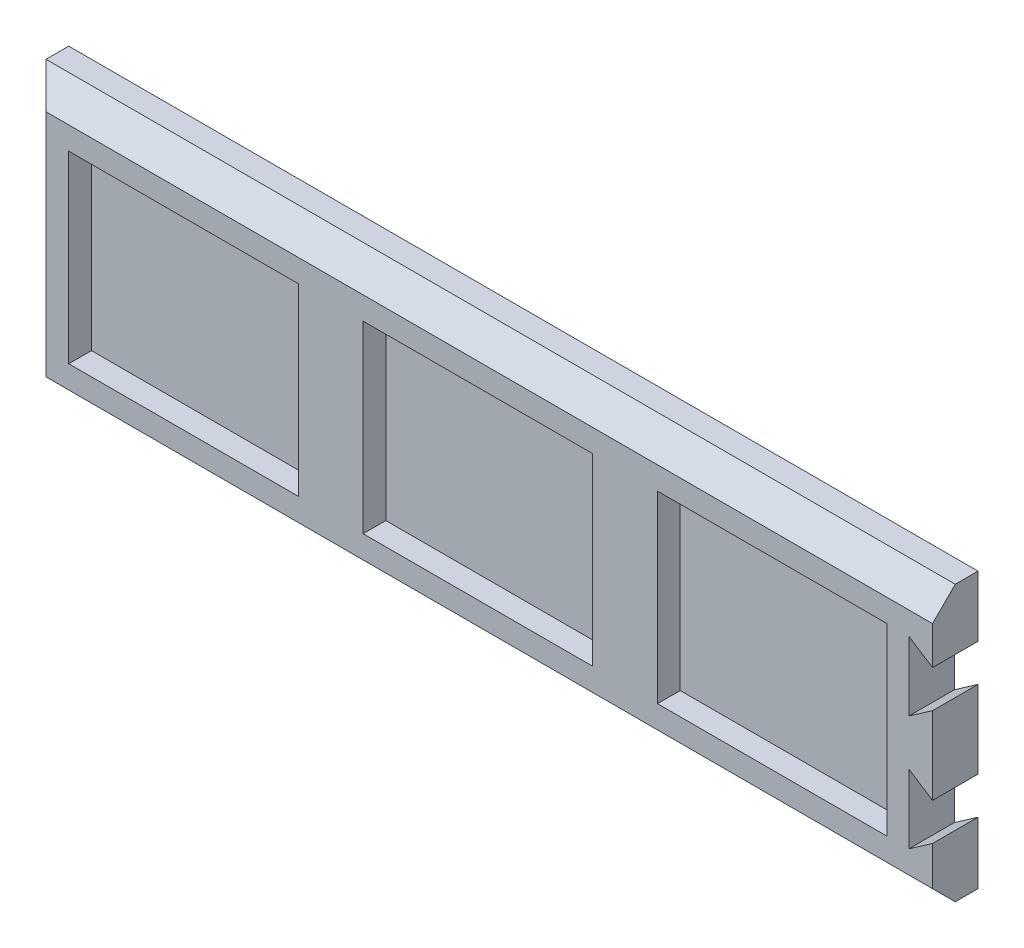
from build123d import *

# Parameters (mm, degrees)
SKIZZE1_W                       = 200
SKIZZE1_H                       = 60.5
AUFSATZ_LINEAR_AUSTRAGEN1_DEPTH = 10
SKIZZE2_W                       = 50.5
SKIZZE2_H                       = 40.5
SCHNITT_LINEAR_AUSTRAGEN1_DEPTH = 5
FASE1_SIZE                      = 5
SCHNITT_LINEAR_AUSTRAGEN2_DEPTH = 10


with BuildPart() as part:
    # Skizze1 → Aufsatz-Linear austragen1 (new body)
    with BuildSketch(Plane.XY):
        with Locations((100, 0)):
            Rectangle(SKIZZE1_W, SKIZZE1_H)
    extrude(amount=AUFSATZ_LINEAR_AUSTRAGEN1_DEPTH)

    # Skizze2 → Schnitt-Linear austragen1 (cut)
    with BuildSketch(Plane.XY.offset(10)):
        with Locations((35.25, 0)):
            Rectangle(SKIZZE2_W, SKIZZE2_H)
        with Locations((100, 0)):
            Rectangle(SKIZZE2_W, SKIZZE2_H)
        with Locations((164.75, 0)):
            Rectangle(SKIZZE2_W, SKIZZE2_H)
    extrude(amount=-SCHNITT_LINEAR_AUSTRAGEN1_DEPTH, mode=Mode.SUBTRACT)

    # Fase1
    fase1_edges = [part.edges().sort_by_distance(p)[0] for p in [
        (100, 30.25, 10),
        (0, 0, 10),
        (100, -30.25, 10),
    ]]
    chamfer(fase1_edges, length=FASE1_SIZE)

    # Skizze4 → Schnitt-Linear austragen2 (cut)
    with BuildSketch(Plane.XY.offset(10)):
        Polygon((200, 16.873625745), (194.8, 20.25), (194.8, 5.05), (200, 8.673625745), align=None)
        Polygon((200, -8.426374255), (194.8, -5.05), (194.8, -20.25), (200, -16.626374255), align=None)
    extrude(amount=-SCHNITT_LINEAR_AUSTRAGEN2_DEPTH, mode=Mode.SUBTRACT)


solid = part.part
